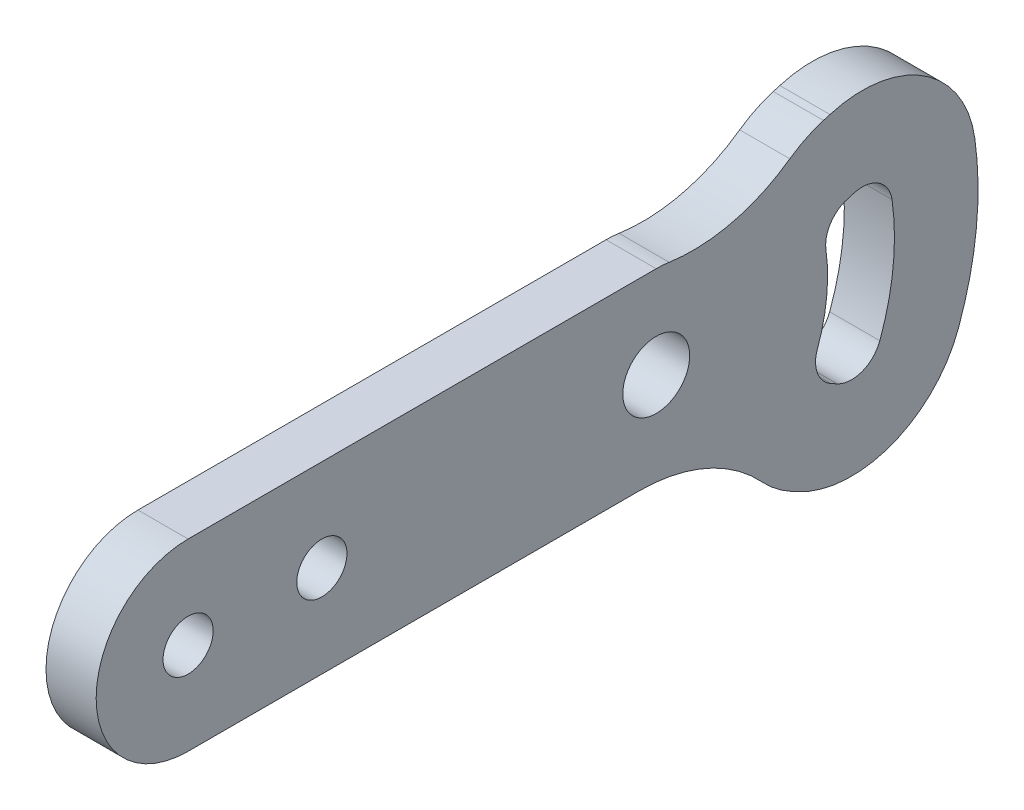
from build123d import *

# Parameters (mm, degrees)
SKETCH1_R           = 1.5
SKETCH1_R_2         = 2
BOSS_EXTRUDE1_DEPTH = 3
FILLET1_R           = 10


with BuildPart() as part:
    # Sketch1 → Boss-Extrude1 (new body)
    with BuildSketch(Plane(origin=(0, 0, 0), x_dir=(0, 0, -1), z_dir=(1, 0, 0))):
        with BuildLine():
            Line((0, 5.5), (28, 5.5))
            ThreePointArc((28, 5.5), (33.5, 0), (28, -5.5))
            Line((28, -5.5), (0, -5.5))
            ThreePointArc((0, -5.5), (-5.5, 0), (0, 5.5))
        make_face()
        Circle(SKETCH1_R, mode=Mode.SUBTRACT)
        with Locations((8, 0)):
            Circle(SKETCH1_R, mode=Mode.SUBTRACT)
        with Locations((28, 0)):
            Circle(SKETCH1_R_2, mode=Mode.SUBTRACT)
        with BuildLine():
            Line((38.004070302, 8.178085192), (38.391808013, 8.292938334))
            ThreePointArc((38.391808013, 8.292938334), (43.99239408, 7.498029345), (47.053808263, 2.741330092))
            ThreePointArc((47.053808263, 2.741330092), (47.144546486, -2.012172918), (46.067482263, -6.642934944))
            ThreePointArc((46.067482263, -6.642934944), (42.08399394, -10.659185108), (36.440523244, -10.272296109))
            Line((36.440523244, -10.272296109), (36.085137843, -10.07933758))
            ThreePointArc((36.085137843, -10.07933758), (32.972810208, -6.517601461), (32.936227504, -1.787780197))
            ThreePointArc((32.936227504, -1.787780197), (33.221239951, -0.548774432), (33.200059493, 0.722413504))
            ThreePointArc((33.200059493, 0.722413504), (34.219227914, 5.341270853), (38.004070302, 8.178085192))
        make_face()
        with BuildLine():
            Line((39.424147025, 3.383986517), (39.811884737, 3.49883966))
            ThreePointArc((39.811884737, 3.49883966), (41.294392813, 3.288422575), (42.104767156, 2.029296302))
            ThreePointArc((42.104767156, 2.029296302), (42.171937009, -1.489530602), (41.374629727, -4.917497297))
            ThreePointArc((41.374629727, -4.917497297), (40.320176936, -5.98062234), (38.826317046, -5.878210546))
            Line((38.826317046, -5.878210546), (38.470931645, -5.685252017))
            ThreePointArc((38.470931645, -5.685252017), (37.647080212, -4.742439515), (37.637396555, -3.490428004))
            ThreePointArc((37.637396555, -3.490428004), (38.193849428, -1.071416748), (38.152497105, 1.410426365))
            ThreePointArc((38.152497105, 1.410426365), (38.422276981, 2.633065075), (39.424147025, 3.383986517))
        make_face(mode=Mode.SUBTRACT)
    extrude(amount=BOSS_EXTRUDE1_DEPTH)

    # Fillet1
    fillet1_edges = [part.edges().sort_by_distance(p)[0] for p in [
        (1.5, -2.978897206, -32.623437188),
        (1.5, 1.952534512, -33.141751548),
    ]]
    fillet(fillet1_edges, radius=FILLET1_R)


solid = part.part
